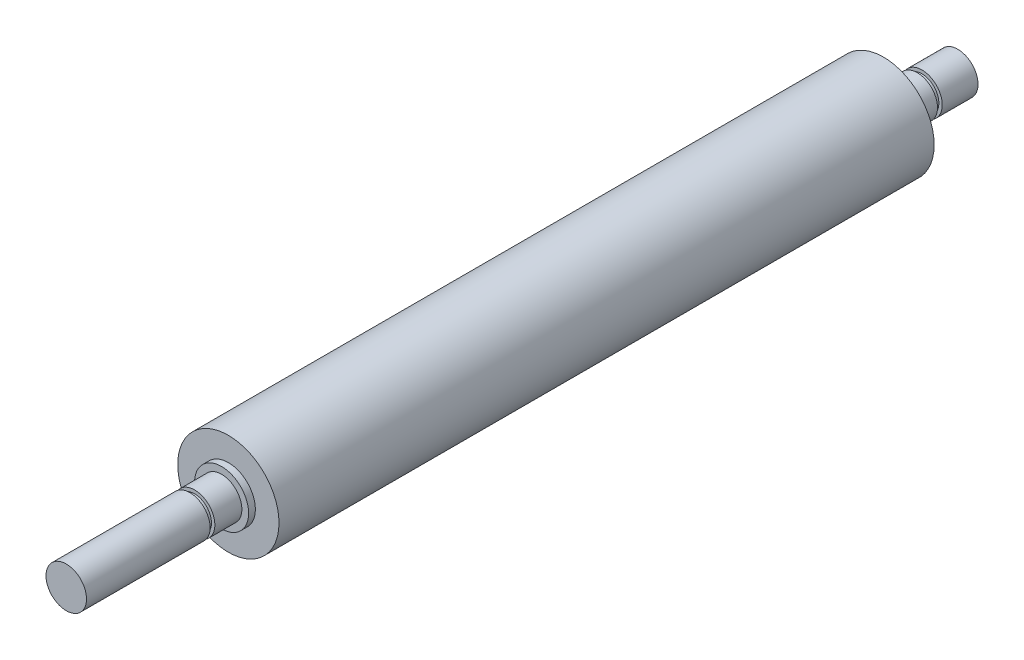
from build123d import *

# Parameters (mm, degrees)
SKETCH_1_R          = 7.5
EXTRUDE_1_DEPTH     = 97
SKETCH_2_R          = 4
EXTRUDE_2_DEPTH     = 1
SKETCH_3_R          = 3
EXTRUDE_3_DEPTH     = 10
SKETCH_4_R          = 4
EXTRUDE_4_DEPTH     = 1
SKETCH_5_R          = 3
EXTRUDE_5_DEPTH     = 23
SKETCH_6_R          = 6.147127497
SKETCH_6_R_2        = 2.5
CUT_EXTRUDE_1_DEPTH = 0.7
SKETCH_7_R          = 6.101942299
SKETCH_7_R_2        = 2.5
CUT_EXTRUDE_2_DEPTH = 0.7


with BuildPart() as part:
    # 草图1 → 凸台-拉伸1 (new body)
    with BuildSketch(Plane.XY):
        Circle(SKETCH_1_R)
    extrude(amount=EXTRUDE_1_DEPTH)

    # 草图2 → 凸台-拉伸2 (add)
    with BuildSketch(Plane(origin=(0, 0, 0), x_dir=(-1, 0, 0), z_dir=(0, 0, -1))):
        Circle(SKETCH_2_R)
    extrude(amount=EXTRUDE_2_DEPTH)

    # 草图3 → 凸台-拉伸3 (add)
    with BuildSketch(Plane(origin=(0, 0, -1), x_dir=(-1, 0, 0), z_dir=(0, 0, -1))):
        Circle(SKETCH_3_R)
    extrude(amount=EXTRUDE_3_DEPTH)

    # 草图4 → 凸台-拉伸4 (add)
    with BuildSketch(Plane.XY.offset(97)):
        Circle(SKETCH_4_R)
    extrude(amount=EXTRUDE_4_DEPTH)

    # 草图5 → 凸台-拉伸5 (add)
    with BuildSketch(Plane.XY.offset(98)):
        Circle(SKETCH_5_R)
    extrude(amount=EXTRUDE_5_DEPTH)

    # 草图6 → 切除-拉伸1 (cut)
    with BuildSketch(Plane(origin=(0, 0, -5), x_dir=(-1, 0, 0), z_dir=(0, 0, -1))):
        Circle(SKETCH_6_R)
        Circle(SKETCH_6_R_2, mode=Mode.SUBTRACT)
    extrude(amount=CUT_EXTRUDE_1_DEPTH, mode=Mode.SUBTRACT)

    # 草图7 → 切除-拉伸2 (cut)
    with BuildSketch(Plane(origin=(0, 0, 102), x_dir=(-1, 0, 0), z_dir=(0, 0, -1))):
        Circle(SKETCH_7_R)
        Circle(SKETCH_7_R_2, mode=Mode.SUBTRACT)
    extrude(amount=-CUT_EXTRUDE_2_DEPTH, mode=Mode.SUBTRACT)


solid = part.part
